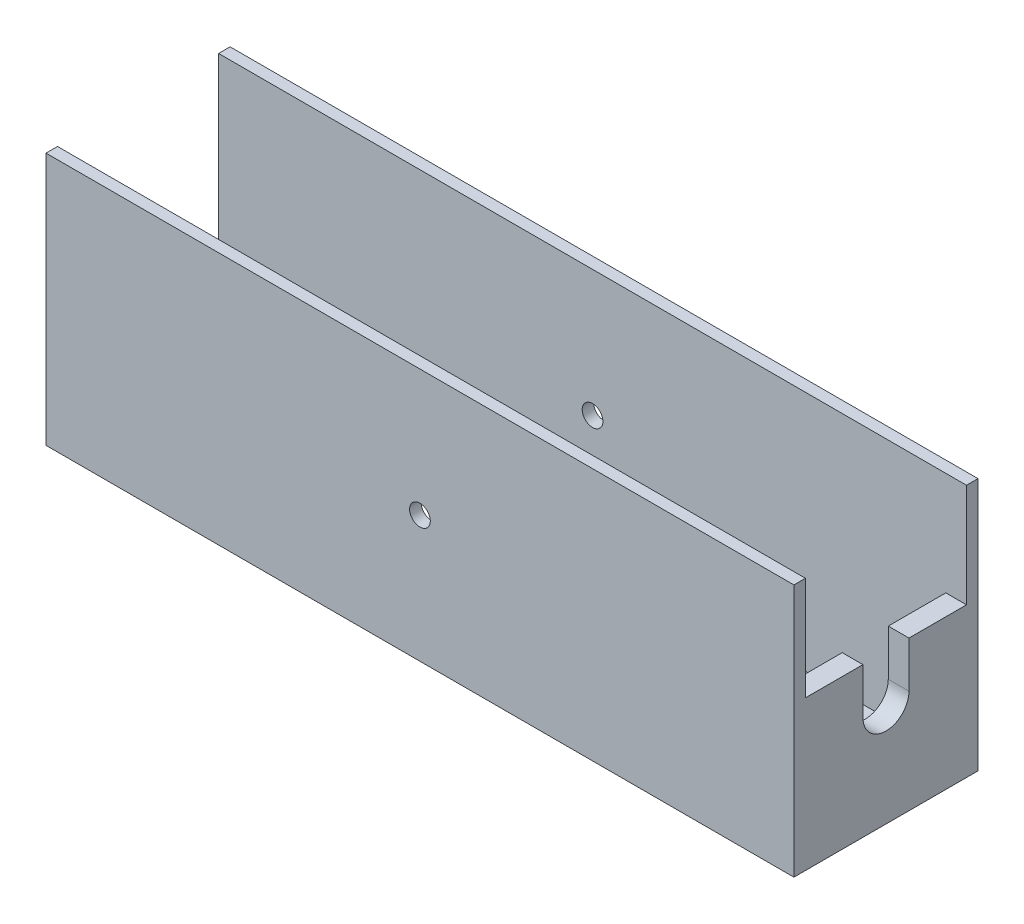
from build123d import *

# Parameters (mm, degrees)
SKETCH1_W               = 325
SKETCH1_H               = 80
BOSS_EXTRUDE1_DEPTH     = 5
BOSS_EXTRUDE2_DEPTH     = 105
SKETCH3_R               = 4.5
CUT_EXTRUDE1_DEPTH      = 1
CUT_EXTRUDE1_DEPTH_BACK = 81
SKETCH4_W               = 120
SKETCH4_H               = 70
CUT_EXTRUDE2_DEPTH      = 105
SKETCH5_W               = 20
SKETCH5_H               = 20
CUT_EXTRUDE3_DEPTH      = 105


with BuildPart() as part:
    # Sketch1 → Boss-Extrude1 (new body)
    with BuildSketch(Plane(origin=(0, 0, 0), x_dir=(1, 0, 0), z_dir=(0, 1, 0))):
        with Locations((0, 45.507641921)):
            Rectangle(SKETCH1_W, SKETCH1_H)
    extrude(amount=-BOSS_EXTRUDE1_DEPTH)

    # Sketch2 → Boss-Extrude2 (add)
    with BuildSketch(Plane(origin=(0, 0, 0), x_dir=(1, 0, 0), z_dir=(0, 1, 0))):
        Polygon((-150.609375415, 80.507641921), (-162.5, 80.507641921), (-162.5, 85.507641921), (162.5, 85.507641921), (162.5, 5.507641921), (-162.5, 5.507641921), (-162.5, 10.507641921), (-150.609375415, 10.507641921), (153.5, 10.507641921), (153.5, 80.507641921), align=None)
    extrude(amount=BOSS_EXTRUDE2_DEPTH)

    # Sketch3 → Cut-Extrude1 (cut, two sides)
    with BuildSketch(Plane.XY.offset(-5.507641921)) as cut_extrude1_sk:
        with Locations((0, 50)):
            Circle(SKETCH3_R)
    extrude(amount=CUT_EXTRUDE1_DEPTH, mode=Mode.SUBTRACT)
    extrude(cut_extrude1_sk.sketch, amount=-CUT_EXTRUDE1_DEPTH_BACK, mode=Mode.SUBTRACT)

    # Sketch4 → Cut-Extrude2 (cut)
    with BuildSketch(Plane(origin=(0, 0, 0), x_dir=(1, 0, 0), z_dir=(0, 1, 0))):
        with Locations((-7.5, 45.507641921)):
            Rectangle(SKETCH4_W, SKETCH4_H)
    extrude(amount=-CUT_EXTRUDE2_DEPTH, mode=Mode.SUBTRACT)

    # Sketch5 → Cut-Extrude3 (cut)
    with BuildSketch(Plane(origin=(162.5, 0, 0), x_dir=(0, 0, -1), z_dir=(1, 0, 0))):
        Polygon((80.507641921, 105), (10.507641921, 105), (10.507641921, 60), (35.507641921, 60), (55.507641921, 60), (80.507641921, 60), align=None)
        with Locations((45.507641921, 50)):
            Rectangle(SKETCH5_W, SKETCH5_H)
        with BuildLine():
            Line((55.507641921, 40), (35.507641921, 40))
            ThreePointArc((35.507641921, 40), (45.507641921, 30), (55.507641921, 40))
        make_face()
    extrude(amount=-CUT_EXTRUDE3_DEPTH, mode=Mode.SUBTRACT)


solid = part.part
